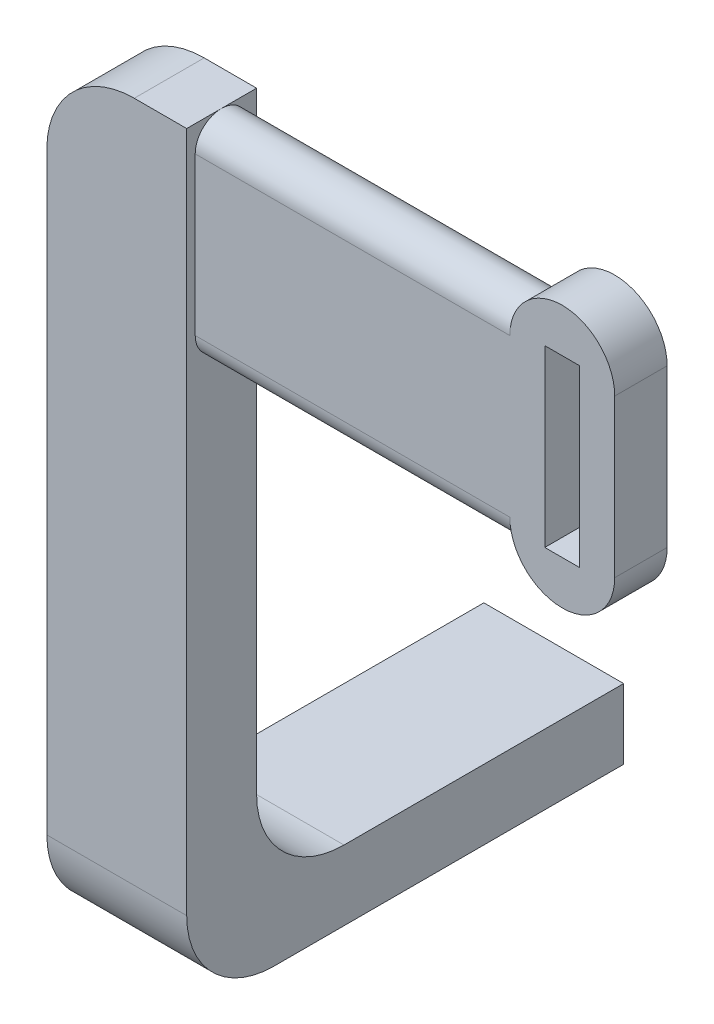
from build123d import *

# Parameters (mm, degrees)
ARM_FEATURE_SKETCH_W = 16
ARM_FEATURE_SKETCH_H = 8
ARM_FEATURE_DEPTH    = 50
TAB_FEATURE_SKETCH_W = 8
TAB_FEATURE_SKETCH_H = 25
TAB_FEATURE_DEPTH    = 5
LEG_FEATURE_SKETCH_W = 16
LEG_FEATURE_SKETCH_H = 8
LEG_FEATURE_DEPTH    = 80
SLOT_FEATURE_DEPTH   = 42
STRAP_FEATURE_DEPTH  = 6
STRAP_CUT_SKETCH_W   = 4
STRAP_CUT_SKETCH_H   = 20
STRAP_CUT_DEPTH      = 6
FILLET1_R            = 10
FILLET2_R            = 10
FILLET3_R            = 10


with BuildPart() as part:
    # Arm Feature Sketch → Arm Feature (new body)
    with BuildSketch(Plane.XY):
        Rectangle(ARM_FEATURE_SKETCH_W, ARM_FEATURE_SKETCH_H)
    extrude(amount=ARM_FEATURE_DEPTH)

    # Tab Feature Sketch → Tab Feature (cut)
    with BuildSketch(Plane(origin=(0, -4, 0), x_dir=(1, 0, 0), z_dir=(0, 1, 0))):
        with Locations((0, -12.5)):
            Rectangle(TAB_FEATURE_SKETCH_W, TAB_FEATURE_SKETCH_H)
    extrude(amount=TAB_FEATURE_DEPTH, mode=Mode.SUBTRACT)

    # Leg Feature Sketch → Leg Feature (add)
    with BuildSketch(Plane(origin=(0, 4, 0), x_dir=(1, 0, 0), z_dir=(0, 1, 0))):
        with Locations((0, -46)):
            Rectangle(LEG_FEATURE_SKETCH_W, LEG_FEATURE_SKETCH_H)
    extrude(amount=LEG_FEATURE_DEPTH)

    # Slot Feature Sketch → Slot Feature (add)
    with BuildSketch(Plane(origin=(8, 0, 0), x_dir=(0, 0, -1), z_dir=(1, 0, 0))):
        with BuildLine():
            Line((-43.025235216, 81), (-43.025235216, 63))
            ThreePointArc((-43.025235216, 63), (-46.025235216, 60), (-49.025235216, 63))
            Line((-49.025235216, 63), (-49.025235216, 81))
            ThreePointArc((-49.025235216, 81), (-46.025235216, 84), (-43.025235216, 81))
        make_face()
    extrude(amount=SLOT_FEATURE_DEPTH)

    # Strap Feature Sketch → Strap Feature (add)
    with BuildSketch(Plane(origin=(0, 0, 43.025235216), x_dir=(-1, 0, 0), z_dir=(0, 0, -1))):
        with BuildLine():
            Line((-56, 63), (-56, 81))
            ThreePointArc((-56, 81), (-50, 87), (-44, 81))
            Line((-44, 81), (-44, 63))
            ThreePointArc((-44, 63), (-50, 57), (-56, 63))
        make_face()
    extrude(amount=-STRAP_FEATURE_DEPTH)

    # Strap Cut Sketch → Strap Cut (cut)
    with BuildSketch(Plane.XY.offset(49.025235216)):
        with Locations((50, 72)):
            Rectangle(STRAP_CUT_SKETCH_W, STRAP_CUT_SKETCH_H)
    extrude(amount=-STRAP_CUT_DEPTH, mode=Mode.SUBTRACT)

    # Fillet1
    fillet1_edges = [part.edges().sort_by_distance(p)[0] for p in [
        (0, -4, 50),
    ]]
    fillet(fillet1_edges, radius=FILLET1_R)

    # Fillet2
    fillet2_edges = [part.edges().sort_by_distance(p)[0] for p in [
        (0, 4, 42),
    ]]
    fillet(fillet2_edges, radius=FILLET2_R)

    # Fillet3
    fillet3_edges = [part.edges().sort_by_distance(p)[0] for p in [
        (-8, 84, 46),
    ]]
    fillet(fillet3_edges, radius=FILLET3_R)


solid = part.part
